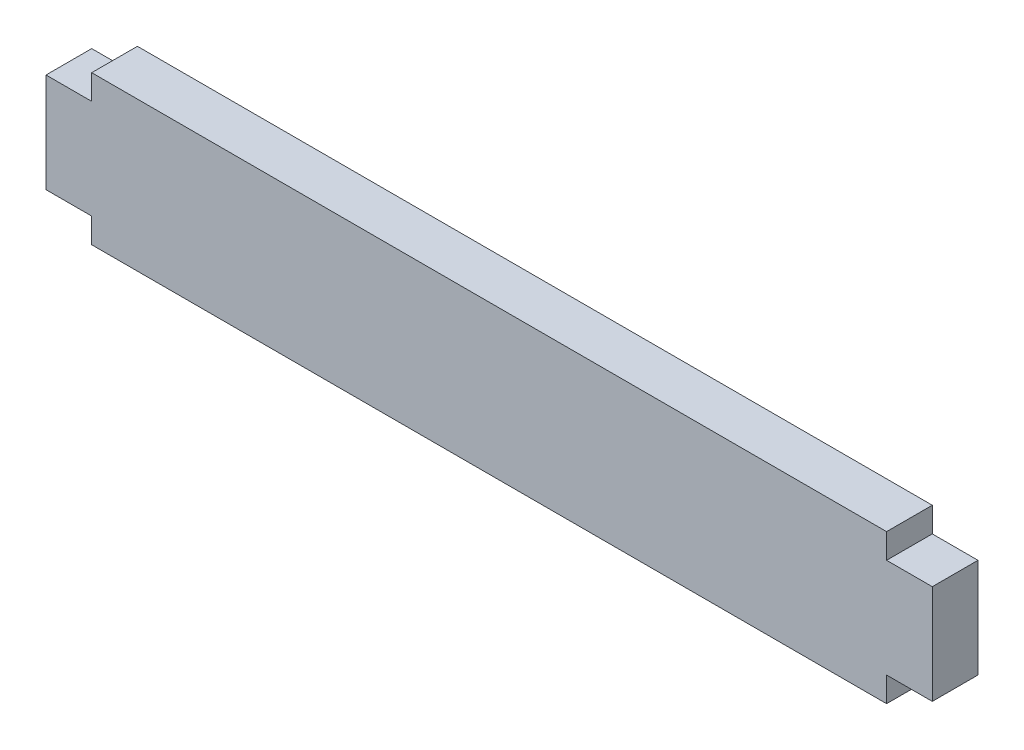
from build123d import *

# Parameters (mm, degrees)
BOSS_EXTRUDE1_DEPTH = 5.842


with BuildPart() as part:
    # Sketch1 → Boss-Extrude1 (new body)
    with BuildSketch(Plane.XY):
        Polygon((56.642, 6.35), (50.8, 6.35), (50.8, 9.525), (-50.8, 9.525), (-50.8, 6.35), (-56.642, 6.35), (-56.642, -6.35), (-50.8, -6.35), (-50.8, -9.525), (50.8, -9.525), (50.8, -6.35), (56.642, -6.35), align=None)
    extrude(amount=BOSS_EXTRUDE1_DEPTH)


solid = part.part
